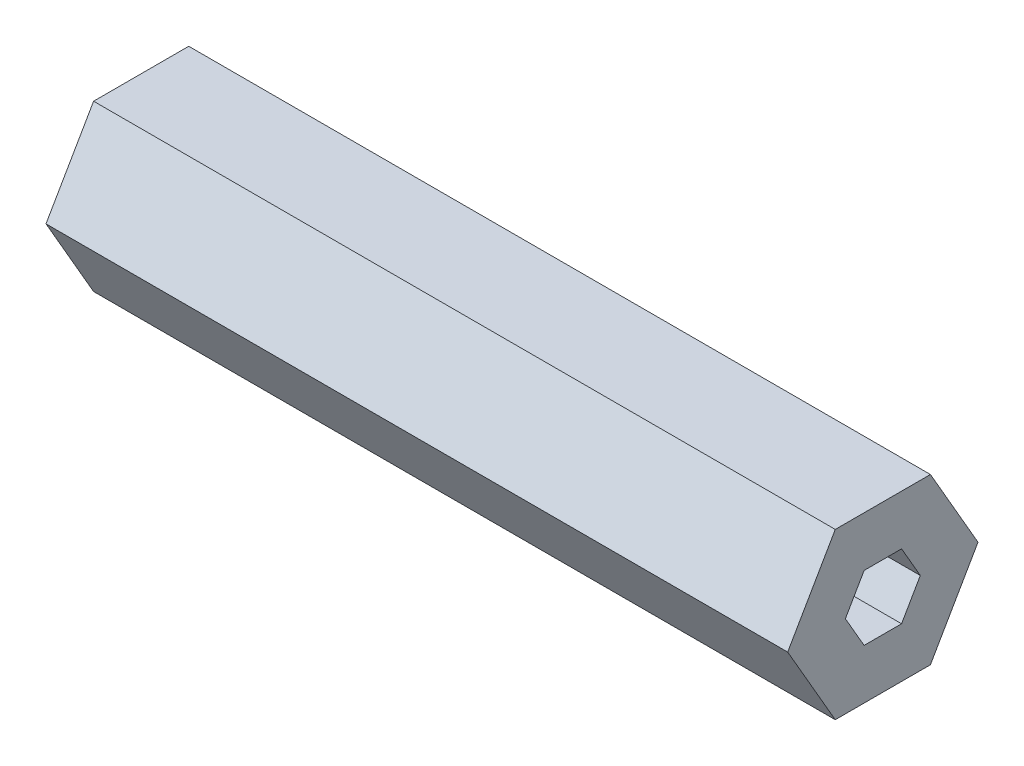
from build123d import *

# Parameters (mm, degrees)
BOSS_EXTRUDE1_DEPTH = 57.15


with BuildPart() as part:
    # Sketch1 → Boss-Extrude1 (new body)
    with BuildSketch(Plane(origin=(0, 0, 0), x_dir=(0, 0, -1), z_dir=(1, 0, 0))):
        Polygon((7.332348419, 0), (3.666174209, 6.35), (-3.666174209, 6.35), (-7.332348419, 0), (-3.666174209, -6.35), (3.666174209, -6.35), align=None)
        Polygon((2.886751346, 0), (1.443375673, 2.5), (-1.443375673, 2.5), (-2.886751346, 0), (-1.443375673, -2.5), (1.443375673, -2.5), align=None, mode=Mode.SUBTRACT)
    extrude(amount=BOSS_EXTRUDE1_DEPTH)


solid = part.part
